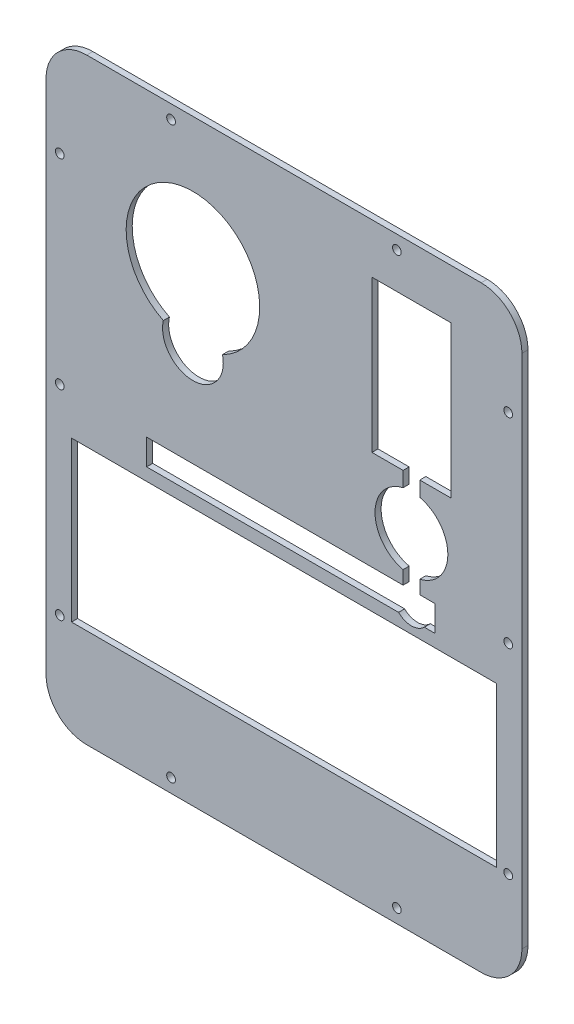
from build123d import *

# Parameters (mm, degrees)
BOSS_EXTRUDE1_DEPTH         = 2.54
CUT_EXTRUDE1_DEPTH          = 3.54
SKETCH7_W                   = 177.8
SKETCH7_H                   = 66.675
CUT_EXTRUDE2_DEPTH          = 3.54
F_27_0_144_DIAMETER_HOLE1_D = 3.6576


with BuildPart() as part:
    # Sketch1 → Boss-Extrude1 (new body)
    with BuildSketch(Plane(origin=(0, 0, 0), x_dir=(0, 1, 0), z_dir=(0, 0, 1))):
        with BuildLine():
            Line((-107.9246, -99.568), (107.9246, -99.568))
            ThreePointArc((107.9246, -99.568), (119.976103714, -94.576103714), (124.968, -82.5246))
            Line((124.968, -82.5246), (124.968, 82.5246))
            ThreePointArc((124.968, 82.5246), (119.976103714, 94.576103714), (107.9246, 99.568))
            Line((107.9246, 99.568), (-107.9246, 99.568))
            ThreePointArc((-107.9246, 99.568), (-119.976103714, 94.576103714), (-124.968, 82.5246))
            Line((-124.968, 82.5246), (-124.968, -82.5246))
            ThreePointArc((-124.968, -82.5246), (-119.976103714, -94.576103714), (-107.9246, -99.568))
        make_face()
    extrude(amount=BOSS_EXTRUDE1_DEPTH)

    # Sketch6 → Cut-Extrude1 (cut, through all)
    with BuildSketch(Plane.XY.offset(2.54)):
        with BuildLine():
            Line((49.8475, 4.691829089), (49.8475, -0.9525))
            Line((49.8475, -0.9525), (-57.4675, -0.9525))
            Line((-57.4675, -0.9525), (-57.4675, -11.7475))
            Line((-57.4675, -11.7475), (47.961208895, -11.7475))
            ThreePointArc((47.961208895, -11.7475), (53.34, -13.97), (58.718791105, -11.7475))
            Line((58.718791105, -11.7475), (63.1825, -11.7475))
            Line((63.1825, -11.7475), (63.1825, -0.9525))
            Line((63.1825, -0.9525), (56.8325, -0.9525))
            Line((56.8325, -0.9525), (56.8325, 4.691829089))
            ThreePointArc((56.8325, 4.691829089), (68.58, 19.52625), (56.8325, 34.360670911))
            Line((56.8325, 34.360670911), (56.8325, 40.64))
            Line((56.8325, 40.64), (69.85, 40.64))
            Line((69.85, 40.64), (69.85, 104.14))
            Line((69.85, 104.14), (36.83, 104.14))
            Line((36.83, 104.14), (36.83, 40.64))
            Line((36.83, 40.64), (49.8475, 40.64))
            Line((49.8475, 40.64), (49.8475, 34.360670911))
            ThreePointArc((49.8475, 34.360670911), (38.1, 19.52625), (49.8475, 4.691829089))
        make_face()
        with BuildLine():
            ThreePointArc((-25.732344403, 44.796363636), (-38.1, 97.79), (-50.467655597, 44.796363636))
            ThreePointArc((-50.467655597, 44.796363636), (-38.1, 29.21), (-25.732344403, 44.796363636))
        make_face()
    extrude(amount=-CUT_EXTRUDE1_DEPTH, mode=Mode.SUBTRACT)

    # Sketch7 → Cut-Extrude2 (cut, through all)
    with BuildSketch(Plane.XY.offset(2.54)):
        with Locations((0, -50.3555)):
            Rectangle(SKETCH7_W, SKETCH7_H)
    extrude(amount=-CUT_EXTRUDE2_DEPTH, mode=Mode.SUBTRACT)

    # #27 (0.144) Diameter Hole1 (through all)
    with Locations(Plane.XY.offset(2.54)):
        with Locations((93.8276, 0), (-93.8276, 0), (47.244, -119.2276), (-47.244, -119.2276), (93.8276, -83.6676), (-93.8276, -83.6676), (-93.8276, 83.6676), (93.8276, 83.6676), (-47.244, 119.2276), (47.244, 119.2276)):
            Hole(F_27_0_144_DIAMETER_HOLE1_D / 2)


solid = part.part
